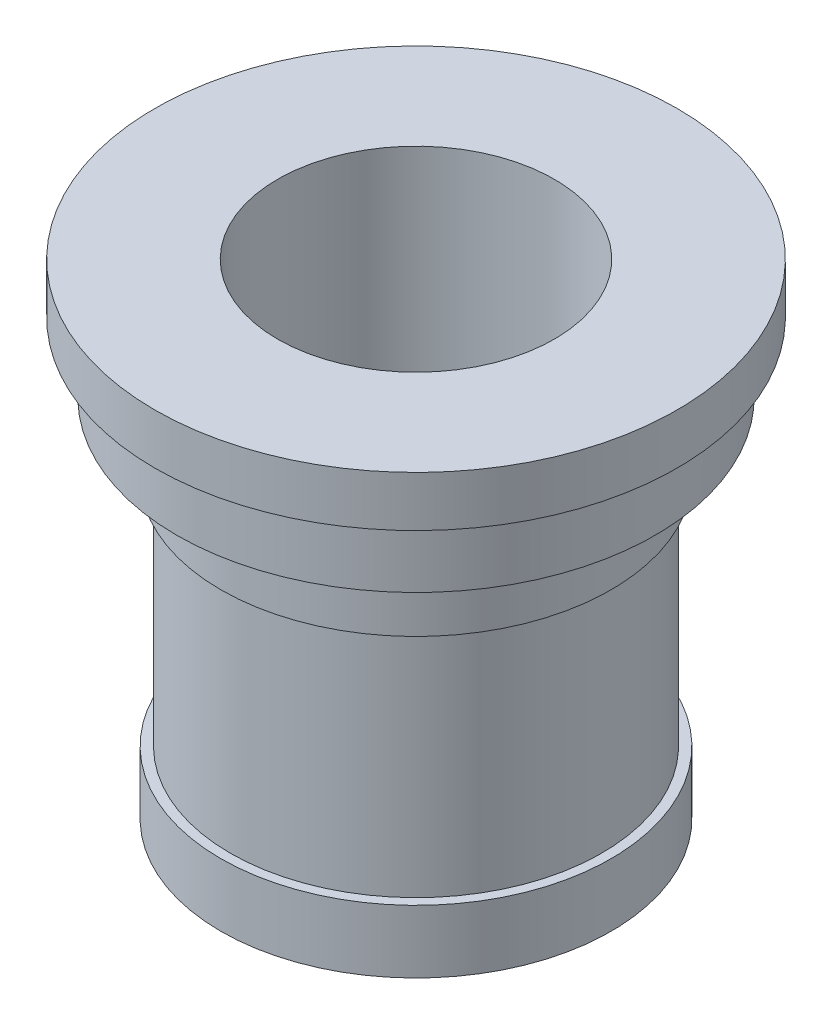
from build123d import *

# Parameters (mm, degrees)
SKETCH1_R           = 31
BOSS_EXTRUDE1_DEPTH = 10
SKETCH2_R           = 29.5
BOSS_EXTRUDE2_DEPTH = 37
SKETCH4_R           = 31
BOSS_EXTRUDE3_DEPTH = 11
SKETCH5_R           = 38
BOSS_EXTRUDE4_DEPTH = 11
SKETCH6_R           = 41.5
BOSS_EXTRUDE5_DEPTH = 8
SKETCH7_R           = 22
CUT_EXTRUDE1_DEPTH  = 78
SKETCH10_R          = 1.5
CUT_EXTRUDE2_DEPTH  = 5


with BuildPart() as part:
    # Sketch1 → Boss-Extrude1 (new body)
    with BuildSketch(Plane(origin=(0, 0, 0), x_dir=(1, 0, 0), z_dir=(0, 1, 0))):
        with Locations(Location((0, 0, 0), (0, 0, 270))):  # turned: the seam where the file's is
            Circle(SKETCH1_R)
    extrude(amount=BOSS_EXTRUDE1_DEPTH)

    # Sketch2 → Boss-Extrude2 (add)
    with BuildSketch(Plane(origin=(0, 10, 0), x_dir=(1, 0, 0), z_dir=(0, 1, 0))):
        with Locations(Location((0, 0, 0), (0, 0, 270))):  # turned: the seam where the file's is
            Circle(SKETCH2_R)
    extrude(amount=BOSS_EXTRUDE2_DEPTH)

    # Sketch4 → Boss-Extrude3 (add)
    with BuildSketch(Plane(origin=(0, 47, 0), x_dir=(1, 0, 0), z_dir=(0, 1, 0))):
        with Locations(Location((0, 0, 0), (0, 0, 270))):  # turned: the seam where the file's is
            Circle(SKETCH4_R)
    extrude(amount=BOSS_EXTRUDE3_DEPTH)

    # Sketch5 → Boss-Extrude4 (add)
    with BuildSketch(Plane(origin=(0, 58, 0), x_dir=(1, 0, 0), z_dir=(0, 1, 0))):
        with Locations(Location((0, 0, 0), (0, 0, 270))):  # turned: the seam where the file's is
            Circle(SKETCH5_R)
    extrude(amount=BOSS_EXTRUDE4_DEPTH)

    # Sketch6 → Boss-Extrude5 (add)
    with BuildSketch(Plane(origin=(0, 69, 0), x_dir=(1, 0, 0), z_dir=(0, 1, 0))):
        with Locations(Location((0, 0, 0), (0, 0, 270))):  # turned: the seam where the file's is
            Circle(SKETCH6_R)
    extrude(amount=BOSS_EXTRUDE5_DEPTH)

    # Sketch7 → Cut-Extrude1 (cut, through all)
    with BuildSketch(Plane(origin=(0, 77, 0), x_dir=(1, 0, 0), z_dir=(0, 1, 0))):
        with Locations(Location((0, 0, 0), (0, 0, 270))):  # turned: the seam where the file's is
            Circle(SKETCH7_R)
    extrude(amount=-CUT_EXTRUDE1_DEPTH, mode=Mode.SUBTRACT)

    # Sketch10 → Cut-Extrude2 (cut)
    with BuildSketch(Plane.XZ):
        with Locations((0, 22)):
            Circle(SKETCH10_R)
    extrude(amount=-CUT_EXTRUDE2_DEPTH, mode=Mode.SUBTRACT)


solid = part.part
